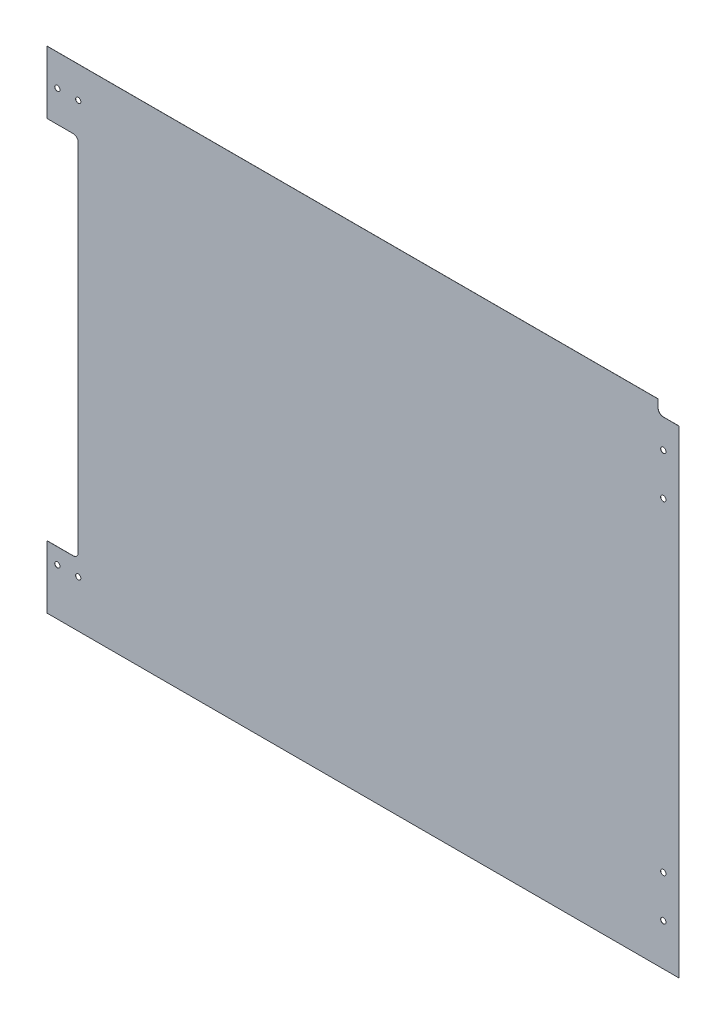
from build123d import *

# Parameters (mm, degrees)
SKETCH1_W                   = 736.6
SKETCH1_H                   = 596.9
BOSS_EXTRUDE1_DEPTH         = 0.127
SKETCH5_W                   = 31.75
SKETCH5_H                   = 76.2
BOSS_EXTRUDE2_DEPTH         = 0.127
SKETCH6_W                   = 6.35
SKETCH6_H                   = 444.5
CUT_EXTRUDE1_DEPTH          = 1.127
FILLET1_R                   = 6.35
F_0_257_DIAMETER_HOLE1_D    = 6.5278
F_1_4_0_25_DIAMETER_HOLE2_D = 6.35
CUT_EXTRUDE2_DEPTH          = 1.127


with BuildPart() as part:
    # Sketch1 → Boss-Extrude1 (new body)
    with BuildSketch(Plane.XY):
        Rectangle(SKETCH1_W, SKETCH1_H)
    extrude(amount=BOSS_EXTRUDE1_DEPTH)

    # Sketch5 → Boss-Extrude2 (add)
    with BuildSketch(Plane.XY.offset(0.127)):
        with Locations((-384.175, 260.35)):
            Rectangle(SKETCH5_W, SKETCH5_H)
        with Locations((-384.175, -260.35)):
            Rectangle(SKETCH5_W, SKETCH5_H)
    extrude(amount=-BOSS_EXTRUDE2_DEPTH)

    # Sketch6 → Cut-Extrude1 (cut, through all)
    with BuildSketch(Plane.XY.offset(0.127)):
        with Locations((-365.125, 0)):
            Rectangle(SKETCH6_W, SKETCH6_H)
    extrude(amount=-CUT_EXTRUDE1_DEPTH, mode=Mode.SUBTRACT)

    # Fillet1
    fillet1_edges = [part.edges().sort_by_distance(p)[0] for p in [
        (-361.95, 222.25, 0.0635),
        (-361.95, -222.25, 0.0635),
    ]]
    fillet(fillet1_edges, radius=FILLET1_R)

    # F (0.257) Diameter Hole1 (through all)
    with Locations(Plane.XY.offset(0.127)):
        with Locations((349.25, 247.65), (349.25, 196.85), (349.25, -196.85), (349.25, -247.65)):
            Hole(F_0_257_DIAMETER_HOLE1_D / 2)

    # 1/4 (0.25) Diameter Hole2 (through all)
    with Locations(Plane.XY.offset(0.127)):
        with Locations((-387.35, 260.35), (-361.95, 260.35), (-361.95, -241.3), (-387.35, -241.3)):
            Hole(F_1_4_0_25_DIAMETER_HOLE2_D / 2)

    # Sketch13 → Cut-Extrude2 (cut, through all)
    with BuildSketch(Plane.XY.offset(0.127)):
        with BuildLine():
            Line((368.3, 298.45), (342.9, 298.45))
            Line((342.9, 298.45), (342.9, 288.925))
            ThreePointArc((342.9, 288.925), (344.759871939, 284.434871939), (349.25, 282.575))
            Line((349.25, 282.575), (368.3, 282.575))
            Line((368.3, 282.575), (368.3, 298.45))
        make_face()
    extrude(amount=-CUT_EXTRUDE2_DEPTH, mode=Mode.SUBTRACT)


solid = part.part
